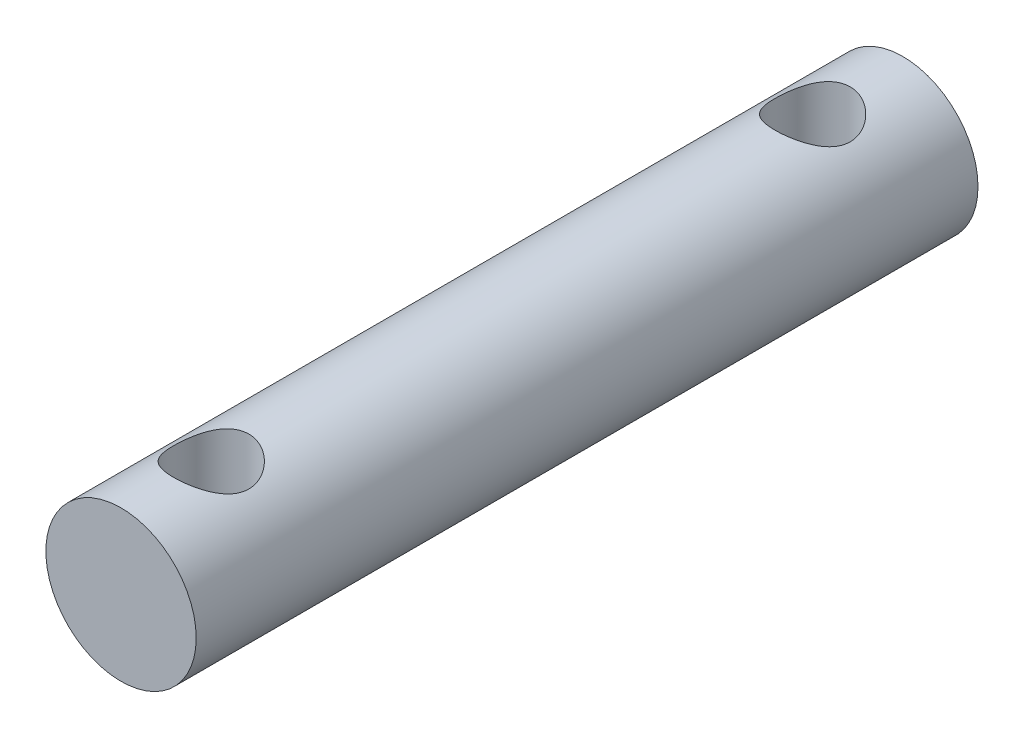
from build123d import *

# Parameters (mm, degrees)
SKETCH1_R               = 2.5
BOSS_EXTRUDE1_DEPTH     = 26
SKETCH2_R               = 1.25
CUT_EXTRUDE1_DEPTH      = 3.5
CUT_EXTRUDE1_DEPTH_BACK = 3.5


with BuildPart() as part:
    # Sketch1 → Boss-Extrude1 (new body)
    with BuildSketch(Plane.XY):
        with Locations((0.77230809, 0)):
            Circle(SKETCH1_R)
    extrude(amount=BOSS_EXTRUDE1_DEPTH)

    # Sketch2 → Cut-Extrude1 (cut, two sides)
    with BuildSketch(Plane(origin=(0, 0, 0), x_dir=(1, 0, 0), z_dir=(0, 1, 0))) as cut_extrude1_sk:
        with Locations((0.77230809, -3)):
            Circle(SKETCH2_R)
        with Locations((0.77230809, -23)):
            Circle(SKETCH2_R)
    extrude(amount=CUT_EXTRUDE1_DEPTH, mode=Mode.SUBTRACT)
    extrude(cut_extrude1_sk.sketch, amount=-CUT_EXTRUDE1_DEPTH_BACK, mode=Mode.SUBTRACT)


solid = part.part
